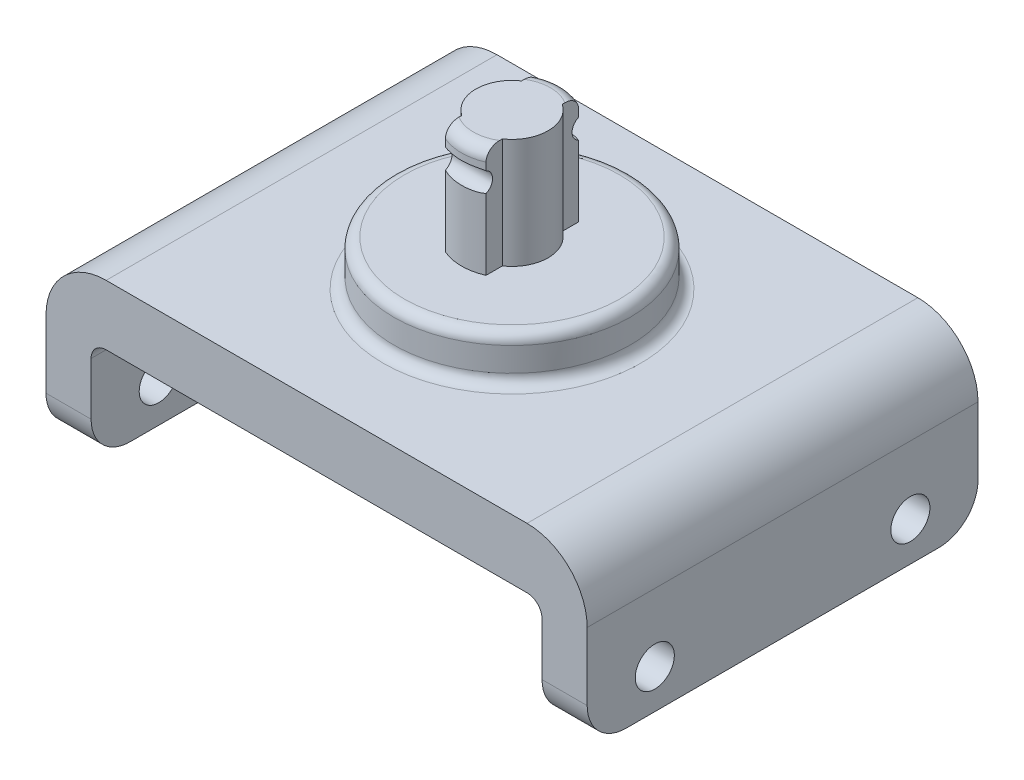
from build123d import *

# Parameters (mm, degrees)
BOSS_EXTRUDE1_DEPTH = 13
SKETCH2_R           = 1.3
CUT_EXTRUDE1_DEPTH  = 37
FILLET1_R           = 1
FILLET2_R           = 2.6
FILLET3_R           = 4
SKETCH3_R           = 7.86
BOSS_EXTRUDE2_DEPTH = 3
FILLET4_R           = 0.7
BOSS_EXTRUDE3_DEPTH = 7.32
SKETCH6_R           = 0.715
CUT_EXTRUDE2_DEPTH  = 20.35
FILLET5_R           = 0.8


with BuildPart() as part:
    # Sketch1 → Boss-Extrude1 (new body, symmetric)
    with BuildSketch(Plane.XY):
        Polygon((-18, 11.1), (18, 11.1), (18, 0), (15, 0), (15, 7.1), (-15, 7.1), (-15, 0), (-18, 0), align=None)
    extrude(amount=BOSS_EXTRUDE1_DEPTH, both=True)

    # Sketch2 → Cut-Extrude1 (cut, through all)
    with BuildSketch(Plane(origin=(18, 0, 0), x_dir=(0, 0, -1), z_dir=(1, 0, 0))):
        with Locations((-8.5, 2.6)):
            Circle(SKETCH2_R)
        with Locations((8.5, 2.6)):
            Circle(SKETCH2_R)
    extrude(amount=-CUT_EXTRUDE1_DEPTH, mode=Mode.SUBTRACT)

    # Fillet1
    fillet1_edges = [part.edges().sort_by_distance(p)[0] for p in [
        (15, 7.1, 0),
        (-15, 7.1, 0),
    ]]
    fillet(fillet1_edges, radius=FILLET1_R)

    # Fillet2
    fillet2_edges = [part.edges().sort_by_distance(p)[0] for p in [
        (-16.5, 0, -13),
        (16.5, 0, 13),
        (-16.5, 0, 13),
        (16.5, 0, -13),
    ]]
    fillet(fillet2_edges, radius=FILLET2_R)

    # Fillet3
    fillet3_edges = [part.edges().sort_by_distance(p)[0] for p in [
        (-18, 11.1, 0),
        (18, 11.1, 0),
    ]]
    fillet(fillet3_edges, radius=FILLET3_R)

    # Sketch3 → Boss-Extrude2 (add)
    with BuildSketch(Plane(origin=(0, 11.1, 0), x_dir=(1, 0, 0), z_dir=(0, 1, 0))):
        Circle(SKETCH3_R)
    extrude(amount=BOSS_EXTRUDE2_DEPTH)

    # Fillet4
    fillet4_edges = [part.edges().sort_by_distance(p)[0] for p in [
        (-7.86, 11.1, 0),
        (-7.86, 14.1, 0),
    ]]
    fillet(fillet4_edges, radius=FILLET4_R)

    # Sketch5 → Boss-Extrude3 (add)
    with BuildSketch(Plane(origin=(0, 14.1, 0), x_dir=(1, 0, 0), z_dir=(0, 1, 0))):
        with BuildLine():
            Line((1.35, 1.990358008), (1.35, 3.076865288))
            ThreePointArc((1.35, 3.076865288), (0, 3.36), (-1.35, 3.076865288))
            Line((-1.35, 3.076865288), (-1.35, 1.990358008))
            ThreePointArc((-1.35, 1.990358008), (-2.405, 0), (-1.35, -1.990358008))
            Line((-1.35, -1.990358008), (-1.35, -3.076865288))
            ThreePointArc((-1.35, -3.076865288), (0, -3.36), (1.35, -3.076865288))
            Line((1.35, -3.076865288), (1.35, -1.990358008))
            ThreePointArc((1.35, -1.990358008), (2.405, 0), (1.35, 1.990358008))
        make_face()
    extrude(amount=BOSS_EXTRUDE3_DEPTH)

    # Sketch6 → Cut-Extrude2 (cut, through all)
    with BuildSketch(Plane(origin=(1.35, 0, 0), x_dir=(0, 0, -1), z_dir=(1, 0, 0))):
        with Locations((-3.36, 19.47)):
            Circle(SKETCH6_R)
        with Locations((3.36, 19.47)):
            Circle(SKETCH6_R)
    extrude(amount=-CUT_EXTRUDE2_DEPTH, mode=Mode.SUBTRACT)

    # Fillet5
    fillet5_edges = [part.edges().sort_by_distance(p)[0] for p in [
        (0, 21.42, 3.36),
        (0, 21.42, -3.36),
    ]]
    fillet(fillet5_edges, radius=FILLET5_R)


solid = part.part
